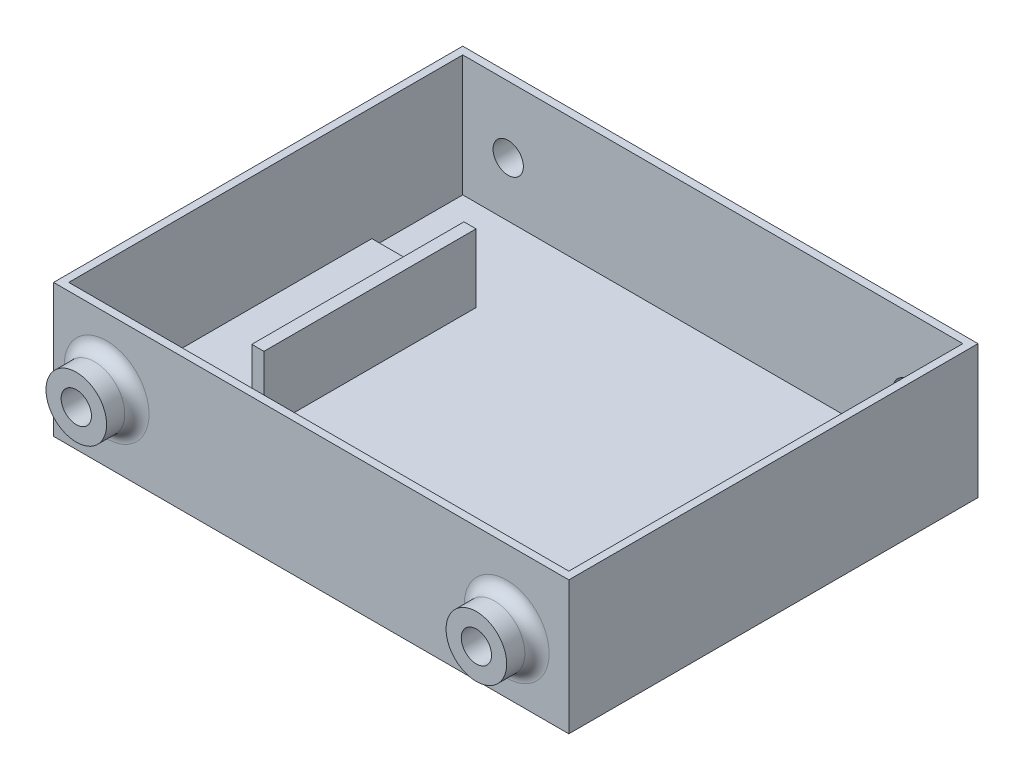
from build123d import *

# Parameters (mm, degrees)
SKETCH1_W               = 107.95
SKETCH1_H               = 85.725
BOSS_EXTRUDE1_DEPTH     = 2.54
SKETCH2_W               = 107.95
SKETCH2_H               = 85.725
SKETCH2_W_2             = 104.775
SKETCH2_H_2             = 82.55
BOSS_EXTRUDE2_DEPTH     = 25.4
SKETCH3_R               = 3.175
CUT_EXTRUDE1_DEPTH      = 141.650708228
CUT_EXTRUDE1_DEPTH_BACK = 141.650708228
SKETCH4_R               = 3.175
CUT_EXTRUDE2_DEPTH      = 141.650708228
CUT_EXTRUDE2_DEPTH_BACK = 141.650708228
SKETCH5_W               = 21.844
SKETCH5_H               = 44.45
BOSS_EXTRUDE3_DEPTH     = 1.5875
SKETCH6_W               = 2.54
SKETCH6_H               = 44.45
BOSS_EXTRUDE4_DEPTH     = 12.7
SKETCH7_R               = 6.35
BOSS_EXTRUDE5_DEPTH     = 6.35
SKETCH8_R               = 6.35
BOSS_EXTRUDE6_DEPTH     = 6.35
FILLET1_R               = 2.54
FILLET2_R               = 2.54
SKETCH9_R               = 6.35
BOSS_EXTRUDE7_DEPTH     = 6.35
SKETCH10_R              = 6.35
BOSS_EXTRUDE8_DEPTH     = 6.35
FILLET3_R               = 2.54
SKETCH11_R              = 3.175
CUT_EXTRUDE4_DEPTH      = 145.608615667
CUT_EXTRUDE4_DEPTH_BACK = 145.608615667
SKETCH12_R              = 3.175
CUT_EXTRUDE5_DEPTH      = 145.608615667
CUT_EXTRUDE5_DEPTH_BACK = 145.608615667


with BuildPart() as part:
    # Sketch1 → Boss-Extrude1 (new body)
    with BuildSketch(Plane(origin=(0, 0, 0), x_dir=(1, 0, 0), z_dir=(0, 1, 0))):
        with Locations((53.975, 42.8625)):
            Rectangle(SKETCH1_W, SKETCH1_H)
    extrude(amount=BOSS_EXTRUDE1_DEPTH)

    # Sketch2 → Boss-Extrude2 (add)
    with BuildSketch(Plane(origin=(0, 2.54, 0), x_dir=(1, 0, 0), z_dir=(0, 1, 0))):
        with Locations((53.975, 42.8625)):
            Rectangle(SKETCH2_W, SKETCH2_H)
        with Locations((53.975, 42.8625)):
            Rectangle(SKETCH2_W_2, SKETCH2_H_2, mode=Mode.SUBTRACT)
    extrude(amount=BOSS_EXTRUDE2_DEPTH)

    # Sketch3 → Cut-Extrude1 (cut, two sides)
    with BuildSketch(Plane(origin=(0, 0, -85.725), x_dir=(-1, 0, 0), z_dir=(0, 0, -1))) as cut_extrude1_sk:
        with Locations((-11.1125, 14.028153998)):
            Circle(SKETCH3_R)
    extrude(amount=CUT_EXTRUDE1_DEPTH, mode=Mode.SUBTRACT)
    extrude(cut_extrude1_sk.sketch, amount=-CUT_EXTRUDE1_DEPTH_BACK, mode=Mode.SUBTRACT)

    # Sketch4 → Cut-Extrude2 (cut, two sides)
    with BuildSketch(Plane(origin=(0, 0, -85.725), x_dir=(-1, 0, 0), z_dir=(0, 0, -1))) as cut_extrude2_sk:
        with Locations((-94.9325, 12.514694303)):
            Circle(SKETCH4_R)
    extrude(amount=CUT_EXTRUDE2_DEPTH, mode=Mode.SUBTRACT)
    extrude(cut_extrude2_sk.sketch, amount=-CUT_EXTRUDE2_DEPTH_BACK, mode=Mode.SUBTRACT)

    # Sketch5 → Boss-Extrude3 (add)
    with BuildSketch(Plane(origin=(0, 2.54, 0), x_dir=(1, 0, 0), z_dir=(0, 1, 0))):
        with Locations((12.5095, 42.8625)):
            Rectangle(SKETCH5_W, SKETCH5_H)
    extrude(amount=BOSS_EXTRUDE3_DEPTH)

    # Sketch6 → Boss-Extrude4 (add)
    with BuildSketch(Plane(origin=(0, 4.1275, 0), x_dir=(1, 0, 0), z_dir=(0, 1, 0))):
        with Locations((22.1615, 42.8625)):
            Rectangle(SKETCH6_W, SKETCH6_H)
    extrude(amount=BOSS_EXTRUDE4_DEPTH)

    # Sketch7 → Boss-Extrude5 (add)
    with BuildSketch(Plane.XY):
        with Locations(Location((11.1125, 14.028153998, 0), (0, 0, 180))):
            Circle(SKETCH7_R)
    extrude(amount=BOSS_EXTRUDE5_DEPTH)

    # Sketch8 → Boss-Extrude6 (add)
    with BuildSketch(Plane.XY):
        with Locations(Location((94.9325, 12.514694303, 0), (0, 0, 180))):
            Circle(SKETCH8_R)
    extrude(amount=BOSS_EXTRUDE6_DEPTH)

    # Fillet1
    fillet1_edges = [part.edges().sort_by_distance(p)[0] for p in [
        (17.4625, 14.028153998, 0),
    ]]
    fillet(fillet1_edges, radius=FILLET1_R)

    # Fillet2
    fillet2_edges = [part.edges().sort_by_distance(p)[0] for p in [
        (101.2825, 12.514694303, 0),
    ]]
    fillet(fillet2_edges, radius=FILLET2_R)

    # Sketch9 → Boss-Extrude7 (add)
    with BuildSketch(Plane(origin=(0, 0, -85.725), x_dir=(-1, 0, 0), z_dir=(0, 0, -1))):
        with Locations((-94.9325, 12.514694303)):
            Circle(SKETCH9_R)
    extrude(amount=BOSS_EXTRUDE7_DEPTH)

    # Sketch10 → Boss-Extrude8 (add)
    with BuildSketch(Plane(origin=(0, 0, -85.725), x_dir=(-1, 0, 0), z_dir=(0, 0, -1))):
        with Locations((-11.1125, 14.028153998)):
            Circle(SKETCH10_R)
    extrude(amount=BOSS_EXTRUDE8_DEPTH)

    # Fillet3
    fillet3_edges = [part.edges().sort_by_distance(p)[0] for p in [
        (101.2825, 12.514694303, -85.725),
        (17.4625, 14.028153998, -85.725),
    ]]
    fillet(fillet3_edges, radius=FILLET3_R)

    # Sketch11 → Cut-Extrude4 (cut, two sides)
    with BuildSketch(Plane.XY.offset(-85.725)) as cut_extrude4_sk:
        with Locations(Location((94.9325, 12.514694303, 0), (0, 0, 180))):
            Circle(SKETCH11_R)
    extrude(amount=CUT_EXTRUDE4_DEPTH, mode=Mode.SUBTRACT)
    extrude(cut_extrude4_sk.sketch, amount=-CUT_EXTRUDE4_DEPTH_BACK, mode=Mode.SUBTRACT)

    # Sketch12 → Cut-Extrude5 (cut, two sides)
    with BuildSketch(Plane.XY.offset(-85.725)) as cut_extrude5_sk:
        with Locations(Location((11.1125, 14.028153998, 0), (0, 0, 180))):
            Circle(SKETCH12_R)
    extrude(amount=CUT_EXTRUDE5_DEPTH, mode=Mode.SUBTRACT)
    extrude(cut_extrude5_sk.sketch, amount=-CUT_EXTRUDE5_DEPTH_BACK, mode=Mode.SUBTRACT)


solid = part.part
